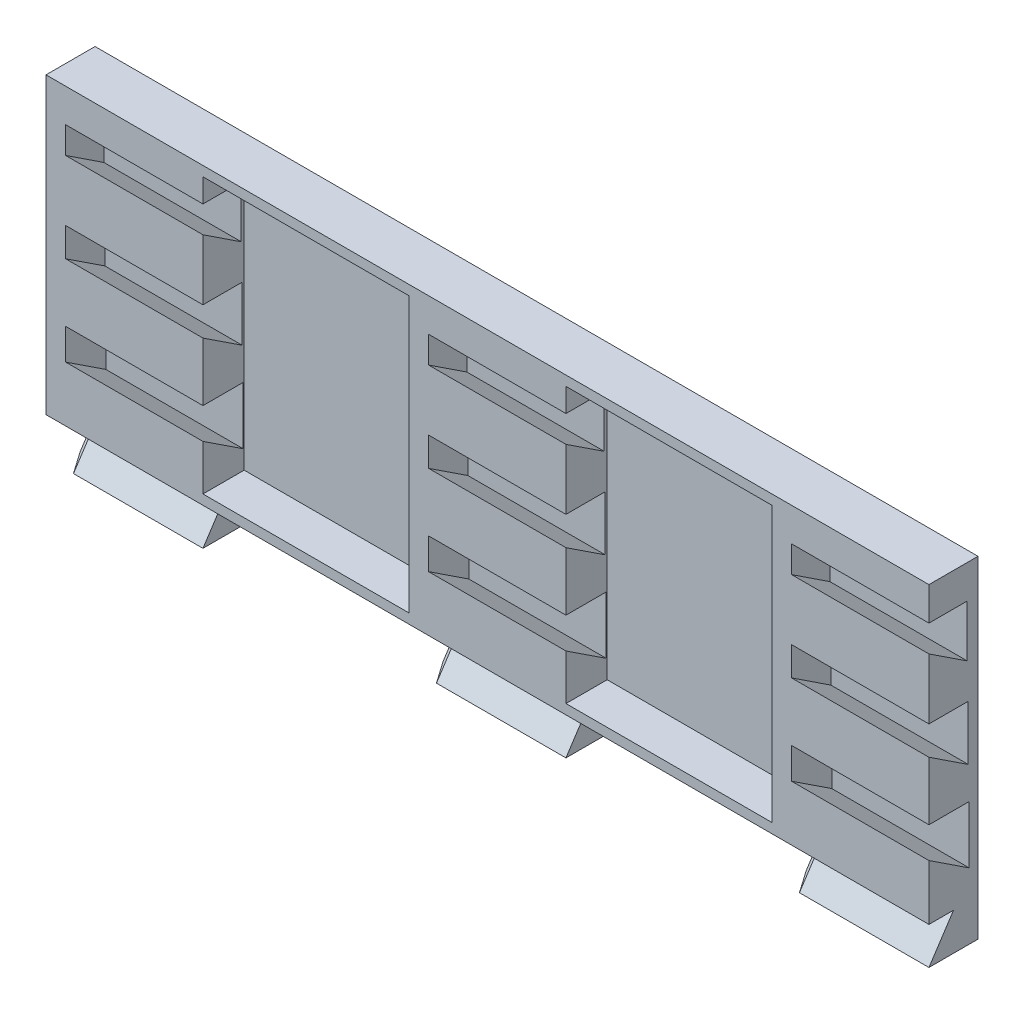
from build123d import *

# Parameters (mm, degrees)
BOSS_EXTRUDE1_DEPTH = 114.3
CUT_EXTRUDE2_DEPTH  = 17.78
LPATTERN2_COUNT     = 3
LPATTERN2_PITCH     = 46.99
SKETCH5_W           = 26.67
SKETCH5_H           = 35.56
CUT_EXTRUDE3_DEPTH  = 5.334
SKETCH6_W           = 2.54
SKETCH6_H           = 4.826
SKETCH6_W_2         = 29.21
CUT_EXTRUDE4_DEPTH  = 7.35
CHAMFER1_SIZE       = 1.016


with BuildPart() as part:
    # Sketch2 → Boss-Extrude1 (new body)
    with BuildSketch(Plane(origin=(0, 0, 0), x_dir=(0, 0, -1), z_dir=(1, 0, 0))):
        Polygon((0, -19.05), (-3.175, -23.876), (3.175, -23.876), (3.175, -19.05), (3.175, 19.05), (-3.175, 19.05), (-3.175, -19.05), align=None)
    extrude(amount=BOSS_EXTRUDE1_DEPTH)

    # Sketch4 → Cut-Extrude2 (cut)
    with BuildSketch(Plane(origin=(114.3, 0, 0), x_dir=(0, 0, -1), z_dir=(1, 0, 0))):
        Polygon((-3.175, 14.732), (-3.175, 11.277980125), (1.778, 8.019427494), (1.778, 14.732), align=None)
        Polygon((-3.175, 3.429), (-3.175, -0.304039749), (1.905, -3.646145012), (1.905, 3.429), align=None)
        Polygon((-3.175, -7.874), (2.032, -7.874), (2.032, -15.311717518), (-3.175, -11.886059624), align=None)
    cut_extrude2 = extrude(amount=-CUT_EXTRUDE2_DEPTH, mode=Mode.SUBTRACT)

    # LPattern2: Cut-Extrude2 ×3
    with Locations(*[(-i * LPATTERN2_PITCH, 0, 0) for i in range(1, LPATTERN2_COUNT)]):
        add(cut_extrude2, mode=Mode.SUBTRACT)

    # Sketch5 → Cut-Extrude3 (cut)
    with BuildSketch(Plane.XY.offset(3.175)):
        with Locations((80.645, 0)):
            Rectangle(SKETCH5_W, SKETCH5_H)
        with Locations((33.655, 0)):
            Rectangle(SKETCH5_W, SKETCH5_H)
    extrude(amount=-CUT_EXTRUDE3_DEPTH, mode=Mode.SUBTRACT)

    # Sketch6 → Cut-Extrude4 (cut, through all)
    with BuildSketch(Plane.XY.offset(3.175)):
        with Locations((1.27, -21.463)):
            Rectangle(SKETCH6_W, SKETCH6_H)
        with Locations((34.925, -21.463)):
            Rectangle(SKETCH6_W_2, SKETCH6_H)
        with Locations((81.915, -21.463)):
            Rectangle(SKETCH6_W_2, SKETCH6_H)
    extrude(amount=-CUT_EXTRUDE4_DEPTH, mode=Mode.SUBTRACT)

    # Chamfer1
    chamfer1_edges = [part.edges().sort_by_distance(p)[0] for p in [
        (2.54, -21.463, 1.5875),
        (2.54, -21.463, -3.175),
        (2.54, -23.876, 0),
        (49.53, -21.463, 1.5875),
        (49.53, -21.463, -3.175),
        (49.53, -23.876, 0),
        (96.52, -21.463, 1.5875),
        (96.52, -21.463, -3.175),
        (96.52, -23.876, 0),
    ]]
    chamfer(chamfer1_edges, length=CHAMFER1_SIZE)


solid = part.part
